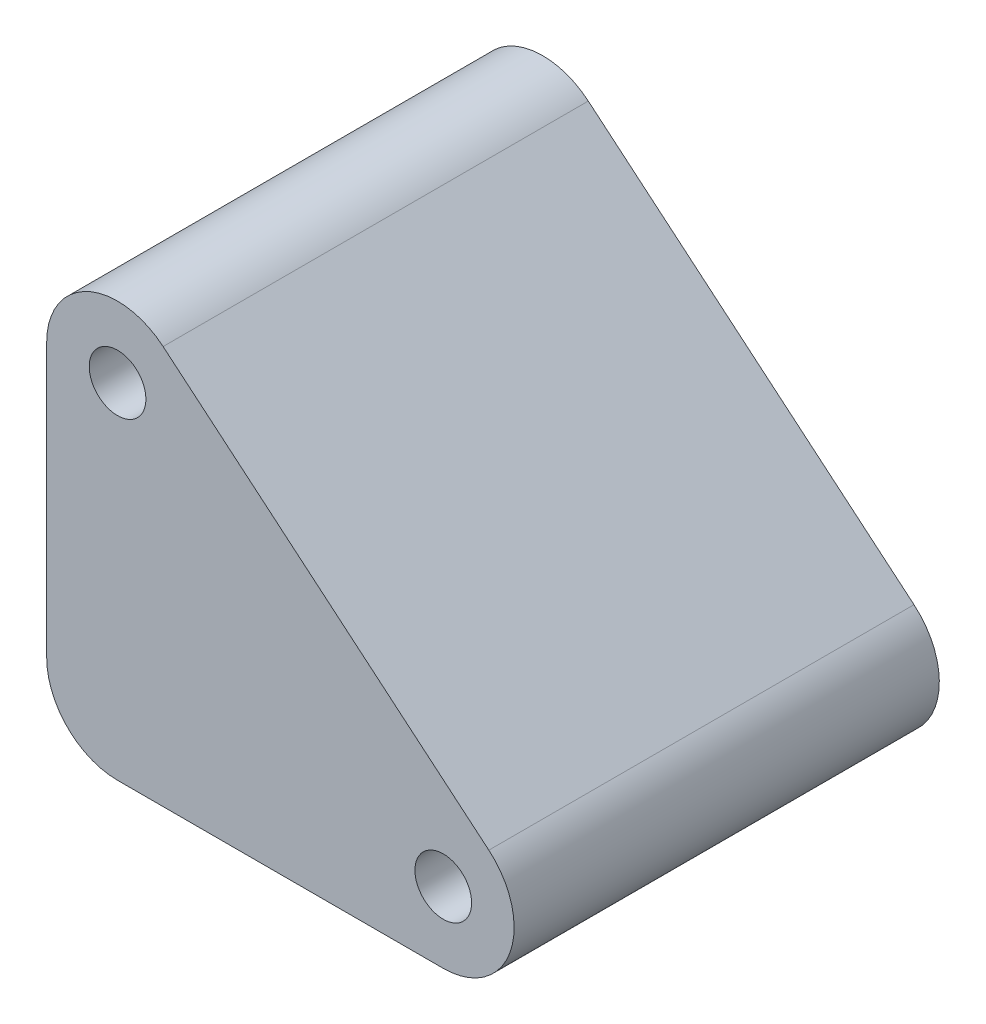
from build123d import *

# Parameters (mm, degrees)
BOSS_EXTRUDE1_DEPTH      = 15
BOSS_EXTRUDE1_DEPTH_BACK = 15
SKETCH1_R                = 2


with BuildPart() as part:
    # Sketch1 → Boss-Extrude1 (new, two sides: drawn at the far end of the back side and taken through both)
    with BuildSketch(Plane.XY.offset(-BOSS_EXTRUDE1_DEPTH_BACK)):
        with BuildLine():
            Line((-250.73011668, 64.896080811), (-227.748783387, 45.61245252))
            ThreePointArc((-227.748783387, 45.61245252), (-226.264258331, 40.072129588), (-230.962721435, 36.782230305))
            Line((-230.962721435, 36.782230305), (-253.944054729, 36.782230305))
            ThreePointArc((-253.944054729, 36.782230305), (-257.479588635, 38.246696399), (-258.944054729, 41.782230305))
            Line((-258.944054729, 41.782230305), (-258.944054729, 61.065858595))
            ThreePointArc((-258.944054729, 61.065858595), (-256.057146037, 65.597397531), (-250.73011668, 64.896080811))
        make_face()
        with Locations((-253.944054729, 61.065858595)):
            Circle(SKETCH1_R, mode=Mode.SUBTRACT)
        with Locations((-230.962721435, 41.782230305)):
            Circle(SKETCH1_R, mode=Mode.SUBTRACT)
    extrude(amount=BOSS_EXTRUDE1_DEPTH + BOSS_EXTRUDE1_DEPTH_BACK)


solid = part.part
